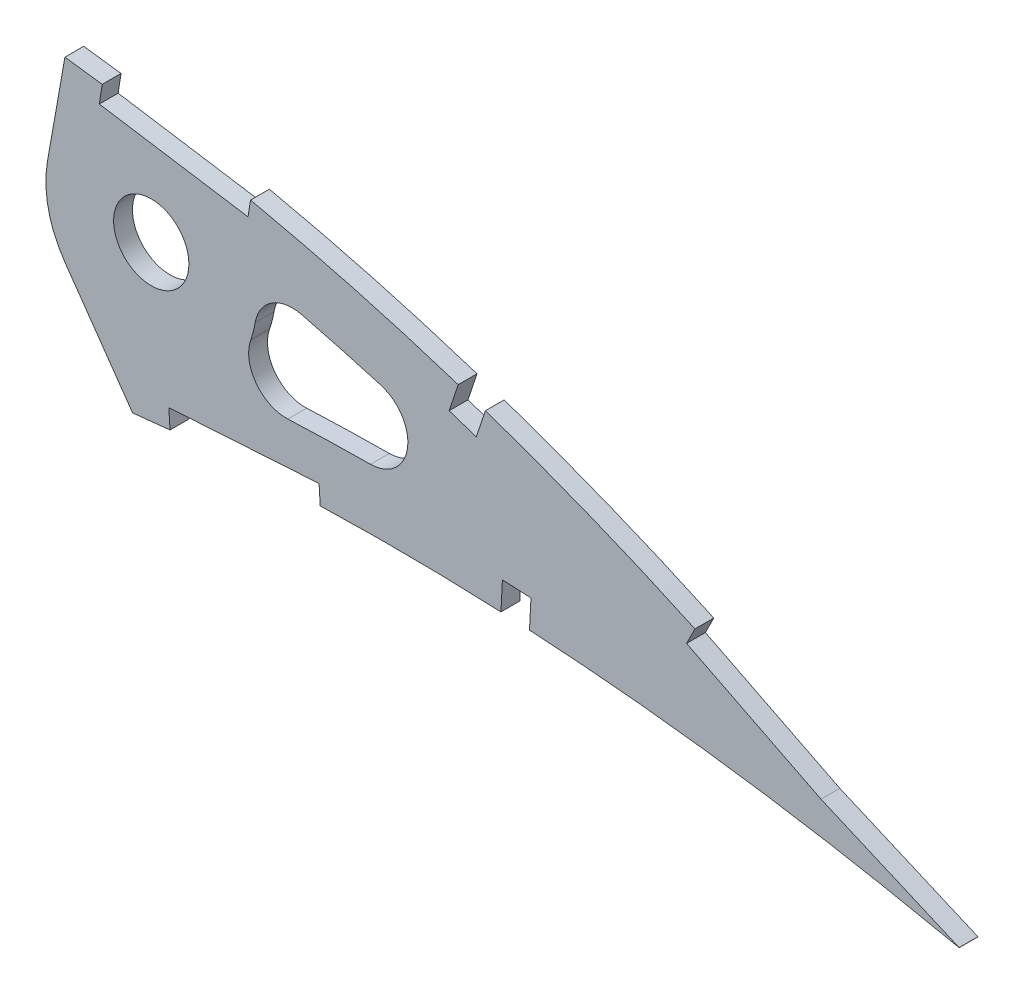
from build123d import *

# Parameters (mm, degrees)
BOSS_EXTRUDE1_DEPTH = 3.175
SKETCH5_R           = 6.35
CUT_EXTRUDE5_DEPTH  = 495.005666426
CUT_EXTRUDE6_DEPTH  = 7.62
FILLET1_R           = 6.35


with BuildPart() as part:
    # Sketch1 → Boss-Extrude1 (new body)
    with BuildSketch(Plane.XY):
        with BuildLine():
            Line((485.587399664, -0.75798934), (490.147728055, -1.684578565))
            Line((490.147728055, -1.684578565), (486.193791136, 0.75798934))
            add(Edge.make_bspline(
                [(486.193791136, 0.75798934), (486.156545565, 0.780998011), (486.007707871, 0.872943377), (485.672349582, 1.078647636), (485.113908292, 1.42125844), (484.332139179, 1.898395939), (483.327649378, 2.508793191), (482.099933618, 3.248176053), (480.649758178, 4.11414228), (478.977474042, 5.102596174), (477.083252712, 6.208909725), (474.9678154, 7.428600903), (472.631346146, 8.754764469), (470.074750091, 10.181981707), (467.298904376, 11.703464898), (464.304334104, 13.312342155), (461.092111509, 15.00042968), (457.663469746, 16.760467008), (454.019033833, 18.582734695), (450.160522056, 20.459648763), (446.08922006, 22.381851369), (441.806517314, 24.339086509), (437.314874314, 26.32337623), (432.615532729, 28.322383702), (427.711170694, 30.327448406), (422.603876177, 32.32715893), (417.296673201, 34.312408193), (411.791609239, 36.270335128), (406.092799427, 38.19238362), (400.203008281, 40.066067188), (394.126447785, 41.881210299), (387.866648542, 43.626044211), (381.42882875, 45.291620487), (374.81707141, 46.865809768), (368.036980395, 48.338075006), (361.093945075, 49.699552264), (353.993788332, 50.936649002), (346.7561854, 52.048400815), (339.497587697, 52.97319004), (332.253923966, 53.880196397), (325.021047815, 54.732245847), (317.699770737, 55.548201081), (310.297136308, 56.323468086), (302.820487344, 57.055622539), (295.277392798, 57.741504683), (287.675691417, 58.379102964), (280.022738792, 58.964804598), (272.326604726, 59.497707184), (264.594897726, 59.973125915), (256.835853078, 60.39070372), (249.05734719, 60.747528421), (241.267474913, 61.041141246), (233.474507978, 61.269769861), (225.686535745, 61.431223873), (217.911990598, 61.524488163), (210.158959277, 61.547014441), (202.435870244, 61.498399603), (194.750810842, 61.376974546), (187.112218127, 61.181076903), (179.528190462, 60.910341158), (172.006928802, 60.56488465), (164.556668167, 60.141814477), (157.185490761, 59.643826715), (149.90160498, 59.068829465), (142.713013757, 58.416669795), (135.627250794, 57.690066178), (128.652204991, 56.887042275), (121.795351463, 56.009883049), (115.064190238, 55.060308222), (108.466273869, 54.03780049), (102.008670179, 52.945313451), (95.69834878, 51.783964779), (89.541985966, 50.557159213), (83.546284377, 49.265216856), (77.717590812, 47.912013041), (72.061962755, 46.499905586), (66.585479912, 45.031479446), (61.293693841, 43.510258272), (56.191955701, 41.93969324), (51.286212878, 40.321510147), (46.580173058, 38.661844322), (42.079617138, 36.961873954), (37.787992638, 35.226836263), (33.71032906, 33.459100147), (29.849672544, 31.664054679), (26.210392495, 29.843743399), (22.795082621, 28.003266258), (19.607171667, 26.145445317), (16.649728276, 24.273731457), (13.923995526, 22.392872215), (11.433731376, 20.504048278), (9.179791317, 18.61203256), (7.163601692, 16.719706143), (5.388044474, 14.828372521), (3.853055719, 12.941362387), (2.560647106, 11.060170164), (1.511042845, 9.186575935), (0.706617001, 7.321940679), (0.14657185, 5.467313049), (-0.159993132, 3.625430402), (-0.236298987, 1.794816138), (-0.078648638, 0.597378122), (0, 0)],
                knots=[0, 0, 0, 0, 0.00025409, 0.001015373, 0.002283359, 0.004056577, 0.006330982, 0.009105274, 0.012374489, 0.016134023, 0.020379661, 0.025105976, 0.030306237, 0.035972206, 0.042099522, 0.048678064, 0.055701664, 0.063160184, 0.071045824, 0.079349827, 0.08806291, 0.097175757, 0.106678111, 0.116561573, 0.126814276, 0.137428301, 0.148393618, 0.15969976, 0.171338125, 0.183297699, 0.195569604, 0.208143556, 0.221011593, 0.234161831, 0.24758745, 0.261276822, 0.27522271, 0.289414144, 0.3037712, 0.317689226, 0.331784111, 0.346039677, 0.36044387, 0.374982721, 0.389640454, 0.404403317, 0.4192566, 0.434186749, 0.449177265, 0.464214782, 0.479284009, 0.49436974, 0.509457833, 0.524532346, 0.53957932, 0.554582984, 0.569529546, 0.584403417, 0.599190992, 0.613876838, 0.628447475, 0.642888675, 0.657186054, 0.671325546, 0.685294014, 0.699078147, 0.712665095, 0.726042645, 0.739197713, 0.752117586, 0.764792042, 0.777208152, 0.789355685, 0.80122396, 0.812803686, 0.824082909, 0.835054602, 0.845709571, 0.856037853, 0.866033834, 0.875688843, 0.884997719, 0.893953426, 0.902552897, 0.910789386, 0.918660734, 0.926166253, 0.933302626, 0.94007122, 0.94647478, 0.952517526, 0.958204819, 0.963546652, 0.9685566, 0.973249913, 0.977651041, 0.981787043, 0.985694226, 0.989415109, 0.993001157, 0.996508416, 1, 1, 1, 1], degree=3))
            add(Edge.make_bspline(
                [(0, 0), (0.124852845, -0.589388692), (0.375132337, -1.770874799), (1.055109044, -3.471725282), (1.954345773, -5.106735278), (3.091715472, -6.671561797), (4.459655687, -8.165777182), (6.055145152, -9.59093561), (7.876619233, -10.946270738), (9.92169391, -12.231165798), (12.187398396, -13.446984767), (14.671186068, -14.592971696), (17.370792198, -15.668768481), (20.283275494, -16.672937055), (23.405075375, -17.607006726), (26.733223776, -18.468701274), (30.263936284, -19.259225009), (33.993816996, -19.976560109), (37.918801514, -20.621435301), (42.034812323, -21.193489669), (46.337624631, -21.693081077), (50.82301706, -22.119161118), (55.4865531, -22.47264634), (60.323584549, -22.753771214), (65.329416188, -22.963427152), (70.499252954, -23.100817142), (75.828031579, -23.168083162), (81.310936338, -23.16623498), (86.942603653, -23.09477832), (92.718222737, -22.957660649), (98.632251256, -22.754013473), (104.679350026, -22.486301136), (110.854064483, -22.157217858), (117.150856575, -21.767879174), (123.564184912, -21.320010643), (130.088480981, -20.817203984), (136.717818035, -20.260713235), (143.446414433, -19.653782206), (150.268313286, -18.999449162), (157.177620607, -18.29978506), (164.168237687, -17.558081099), (171.233938121, -16.77674083), (178.368711149, -15.959932594), (185.566039209, -15.10913432), (192.819836156, -14.229203613), (200.123278023, -13.321821748), (207.470257634, -12.390483576), (214.854167095, -11.43957439), (222.268093801, -10.46898568), (229.705802131, -9.485632582), (237.16011938, -8.488705064), (244.624557097, -7.483330472), (252.092205531, -6.472633763), (259.555791095, -5.456925983), (267.00875308, -4.440416464), (274.444177456, -3.425895825), (281.854781181, -2.413456633), (289.233859631, -1.408131206), (296.573982386, -0.40979664), (303.868380953, 0.579523), (311.110065241, 1.55687475), (318.292203182, 2.521024953), (325.407385919, 3.471363717), (332.448454941, 4.408247897), (339.302915498, 5.303240759), (345.952856872, 6.204000824), (352.420688138, 6.942424504), (358.80798662, 7.572695641), (365.121387221, 8.089431053), (371.353308903, 8.500064921), (377.496611311, 8.807531395), (383.543972889, 9.016123146), (389.487754946, 9.132028332), (395.320533551, 9.158188245), (401.034347101, 9.102945563), (406.621764277, 8.970753247), (412.074986888, 8.767544827), (417.386407281, 8.500176147), (422.548480993, 8.175935919), (427.553458197, 7.799606866), (432.394364707, 7.379974648), (437.06373176, 6.923182232), (441.554389355, 6.434448486), (445.859785012, 5.92401425), (449.973027478, 5.395240442), (453.887929886, 4.85681652), (457.598190253, 4.314198878), (461.097932514, 3.774315295), (464.381658048, 3.242315892), (467.444062607, 2.72526199), (470.280349076, 2.227984348), (472.885595604, 1.755339323), (475.25618804, 1.313290259), (477.38744454, 0.904033197), (479.2765147, 0.534312721), (480.919885909, 0.205760173), (482.315149055, -0.076995438), (483.459867496, -0.312838295), (484.352302675, -0.497896754), (484.990691913, -0.632466588), (485.3743447, -0.712542465), (485.54480657, -0.748903783), (485.587399664, -0.75798934)],
                knots=[0, 0, 0, 0, 0.003638255, 0.007293231, 0.011028136, 0.014901081, 0.018963272, 0.023258475, 0.027820626, 0.032679082, 0.03785316, 0.043361875, 0.049214679, 0.055422346, 0.061988786, 0.068918036, 0.076211157, 0.083868392, 0.091887411, 0.100265912, 0.108999867, 0.118084529, 0.127514843, 0.13728527, 0.147387917, 0.157816481, 0.168563473, 0.179619128, 0.190977373, 0.202626974, 0.214560478, 0.226767249, 0.239236417, 0.251959004, 0.264923894, 0.278119703, 0.291536035, 0.30516028, 0.318980685, 0.332985499, 0.34716279, 0.361498603, 0.375980747, 0.390597192, 0.405332593, 0.420174823, 0.435109533, 0.450124276, 0.465203068, 0.480333154, 0.495500583, 0.510689775, 0.525887334, 0.541078314, 0.556247233, 0.571381785, 0.58646604, 0.601484516, 0.616424329, 0.631269423, 0.646006524, 0.660620684, 0.675098188, 0.689422858, 0.703581824, 0.716907564, 0.730009274, 0.742952128, 0.755725558, 0.768319952, 0.780724337, 0.792926528, 0.804916041, 0.816679084, 0.828203524, 0.8394749, 0.850481359, 0.861207697, 0.871639326, 0.881763414, 0.891563605, 0.901027364, 0.910138977, 0.918883976, 0.927249278, 0.935221104, 0.942784738, 0.949928188, 0.956638464, 0.962904204, 0.968712288, 0.974054485, 0.978918432, 0.983297218, 0.987180246, 0.990560674, 0.993433357, 0.995790626, 0.997629587, 0.998945816, 0.999736592, 1, 1, 1, 1], degree=3))
        make_face()
    extrude(amount=BOSS_EXTRUDE1_DEPTH)

    # Sketch5 → Cut-Extrude5 (cut, through all)
    with BuildSketch(Plane.XY.offset(3.175)):
        with BuildLine():
            ThreePointArc((339.268396528, 23.034385848), (336.474376869, 29.38427855), (336.323038027, 36.320039485))
            Line((336.323038027, 36.320039485), (337.498487212, 42.986343077))
            add(Edge.make_bspline(
                [(337.498487212, 42.986343077), (336.278152634, 43.139647538), (332.391488029, 43.620196944), (325.904912581, 44.406094195), (315.298273289, 45.600903446), (296.745114657, 47.495867579), (270.181386899, 49.613569583), (238.27192568, 51.14645634), (206.363976303, 51.567435326), (174.513649112, 50.743648416), (142.802349779, 48.487430078), (116.596999548, 45.208024241), (95.874041908, 41.555390759), (80.504896847, 38.236322777), (65.37423895, 34.251152388), (53.057700329, 30.27887773), (43.488361933, 26.624824058), (36.49970262, 23.615604654), (29.771075012, 20.304580366), (23.420053123, 16.651798981), (17.654269216, 12.627589389), (13.676813746, 8.984261083), (11.42081563, 6.111975482), (10.531325996, 4.511244861), (10.142088352, 3.437918571), (10.030186656, 2.955882386), (9.973111845, 2.506731868), (9.964230355, 2.311379475), (9.965626151, 2.250431179), (9.965748425, 2.235894656), (9.979062349, 2.081139294), (9.999561737, 1.900153689), (10.01479215, 1.776251195), (10.022081403, 1.718513094)],
                knots=[0.305053467, 0.305053467, 0.305053467, 0.305053467, 0.312228521, 0.327839947, 0.343451373, 0.374674225, 0.43711993, 0.499565634, 0.562011338, 0.624457042, 0.686902747, 0.749348451, 0.780571303, 0.811794155, 0.843017007, 0.874239859, 0.889851285, 0.905462711, 0.921074137, 0.936685563, 0.952296989, 0.967908416, 0.975714129, 0.983519842, 0.987422698, 0.991325555, 0.993276983, 0.995228411, 0.996204125, 0.997179839, 0.998155554, 0.998643411, 0.999131268, 0.999131268, 0.999131268, 0.999131268], degree=3))
            add(Edge.make_bspline(
                [(10.022081403, 1.718513094), (10.034021258, 1.663582679), (10.059908876, 1.546240109), (10.099905998, 1.372347634), (10.138895711, 1.219939682), (10.147564794, 1.192139161), (10.162831137, 1.145171589), (10.226818816, 0.98158475), (10.420263023, 0.586195803), (10.678139358, 0.166718059), (11.33982612, -0.673027549), (12.617971369, -1.866961157), (15.48090731, -3.803568819), (20.158618023, -5.983515642), (26.591355841, -8.02264804), (33.467520416, -9.595157776), (40.598540213, -10.784979213), (47.887704976, -11.668508509), (57.743873902, -12.505919916), (70.236833849, -13.024977368), (85.364632385, -13.028238208), (100.567613906, -12.557423456), (120.895656611, -11.432950706), (146.365626994, -9.289849376), (176.964190047, -5.968711499), (207.58885852, -2.174326754), (238.230999695, 1.888378785), (268.90490631, 6.071067455), (294.483360923, 9.565962325), (312.408562259, 11.98457976), (322.649403588, 13.353359362), (329.053674924, 14.207079569), (334.190701115, 14.88180207), (338.002648093, 15.383326298), (341.277737229, 15.824216257), (343.326113059, 16.089556081), (344.065613823, 16.18324953)],
                knots=[0.000904794, 0.000904794, 0.000904794, 0.000904794, 0.001392633, 0.001880473, 0.002856152, 0.00383183, 0.004807509, 0.006758867, 0.008710225, 0.012612941, 0.016515656, 0.024321088, 0.032126519, 0.047737381, 0.063348244, 0.078959107, 0.094569969, 0.110180832, 0.125791694, 0.15701342, 0.188235145, 0.21945687, 0.250678595, 0.313122046, 0.375565496, 0.438008946, 0.500452397, 0.562895847, 0.625339298, 0.656561023, 0.672171885, 0.687782748, 0.695588179, 0.703393611, 0.711199042, 0.71558295, 0.71558295, 0.71558295, 0.71558295], degree=3))
            Line((344.065613823, 16.18324953), (339.268396528, 23.034385848))
        make_face()
        with Locations((353.832919875, 33.232574886)):
            Circle(SKETCH5_R)
        with BuildLine():
            add(Edge.make_bspline(
                [(337.498487212, 42.986343077), (336.278152634, 43.139647538), (332.391488029, 43.620196944), (325.904912581, 44.406094195), (315.298273289, 45.600903446), (296.745114657, 47.495867579), (270.181386899, 49.613569583), (238.27192568, 51.14645634), (206.363976303, 51.567435326), (174.513649112, 50.743648416), (142.802349779, 48.487430078), (116.596999548, 45.208024241), (95.874041908, 41.555390759), (80.504896847, 38.236322777), (65.37423895, 34.251152388), (53.057700329, 30.27887773), (43.488361933, 26.624824058), (36.49970262, 23.615604654), (29.771075012, 20.304580366), (23.420053123, 16.651798981), (17.654269216, 12.627589389), (13.676813746, 8.984261083), (11.42081563, 6.111975482), (10.531325996, 4.511244861), (10.142088352, 3.437918571), (10.030186656, 2.955882386), (9.973111845, 2.506731868), (9.964230355, 2.311379475), (9.965626151, 2.250431179), (9.965748425, 2.235894656), (9.979062349, 2.081139294), (9.999561737, 1.900153689), (10.01479215, 1.776251195), (10.022081403, 1.718513094)],
                knots=[0.305053467, 0.305053467, 0.305053467, 0.305053467, 0.312228521, 0.327839947, 0.343451373, 0.374674225, 0.43711993, 0.499565634, 0.562011338, 0.624457042, 0.686902747, 0.749348451, 0.780571303, 0.811794155, 0.843017007, 0.874239859, 0.889851285, 0.905462711, 0.921074137, 0.936685563, 0.952296989, 0.967908416, 0.975714129, 0.983519842, 0.987422698, 0.991325555, 0.993276983, 0.995228411, 0.996204125, 0.997179839, 0.998155554, 0.998643411, 0.999131268, 0.999131268, 0.999131268, 0.999131268], degree=3))
            Line((337.498487212, 42.986343077), (339.264168094, 53.000016967))
            add(Edge.make_bspline(
                [(339.264168094, 53.000016967), (336.937656328, 53.293724364), (332.201167732, 53.886411202), (325.021047815, 54.732245847), (317.699770737, 55.548201081), (310.297136308, 56.323468086), (302.820487344, 57.055622539), (295.277392798, 57.741504683), (287.675691417, 58.379102964), (280.022738792, 58.964804598), (272.326604726, 59.497707184), (264.594897726, 59.973125915), (256.835853078, 60.39070372), (249.05734719, 60.747528421), (241.267474913, 61.041141246), (233.474507978, 61.269769861), (225.686535745, 61.431223873), (217.911990598, 61.524488163), (210.158959277, 61.547014441), (202.435870244, 61.498399603), (194.750810842, 61.376974546), (187.112218127, 61.181076903), (179.528190462, 60.910341158), (172.006928802, 60.56488465), (164.556668167, 60.141814477), (157.185490761, 59.643826715), (149.90160498, 59.068829465), (142.713013757, 58.416669795), (135.627250794, 57.690066178), (128.652204991, 56.887042275), (121.795351463, 56.009883049), (115.064190238, 55.060308222), (108.466273869, 54.03780049), (102.008670179, 52.945313451), (95.69834878, 51.783964779), (89.541985966, 50.557159213), (83.546284377, 49.265216856), (77.717590812, 47.912013041), (72.061962755, 46.499905586), (66.585479912, 45.031479446), (61.293693841, 43.510258272), (56.191955701, 41.93969324), (51.286212878, 40.321510147), (46.580173058, 38.661844322), (42.079617138, 36.961873954), (37.787992638, 35.226836263), (33.71032906, 33.459100147), (29.849672544, 31.664054679), (26.210392495, 29.843743399), (22.795082621, 28.003266258), (19.607171667, 26.145445317), (16.649728276, 24.273731457), (13.923995526, 22.392872215), (11.433731376, 20.504048278), (9.179791317, 18.61203256), (7.163601692, 16.719706143), (5.388044474, 14.828372521), (3.853055719, 12.941362387), (2.560647106, 11.060170164), (1.511042845, 9.186575935), (0.706617001, 7.321940679), (0.14657185, 5.467313049), (-0.159993132, 3.625430402), (-0.236298987, 1.794816138), (-0.078648638, 0.597378122), (0, 0)],
                knots=[0.304079504, 0.304079504, 0.304079504, 0.304079504, 0.317689226, 0.331784111, 0.346039677, 0.36044387, 0.374982721, 0.389640454, 0.404403317, 0.4192566, 0.434186749, 0.449177265, 0.464214782, 0.479284009, 0.49436974, 0.509457833, 0.524532346, 0.53957932, 0.554582984, 0.569529546, 0.584403417, 0.599190992, 0.613876838, 0.628447475, 0.642888675, 0.657186054, 0.671325546, 0.685294014, 0.699078147, 0.712665095, 0.726042645, 0.739197713, 0.752117586, 0.764792042, 0.777208152, 0.789355685, 0.80122396, 0.812803686, 0.824082909, 0.835054602, 0.845709571, 0.856037853, 0.866033834, 0.875688843, 0.884997719, 0.893953426, 0.902552897, 0.910789386, 0.918660734, 0.926166253, 0.933302626, 0.94007122, 0.94647478, 0.952517526, 0.958204819, 0.963546652, 0.9685566, 0.973249913, 0.977651041, 0.981787043, 0.985694226, 0.989415109, 0.993001157, 0.996508416, 1, 1, 1, 1], degree=3))
            add(Edge.make_bspline(
                [(0, 0), (0.124852845, -0.589388692), (0.375132337, -1.770874799), (1.055109044, -3.471725282), (1.954345773, -5.106735278), (3.091715472, -6.671561797), (4.459655687, -8.165777182), (6.055145152, -9.59093561), (7.876619233, -10.946270738), (9.92169391, -12.231165798), (12.187398396, -13.446984767), (14.671186068, -14.592971696), (17.370792198, -15.668768481), (20.283275494, -16.672937055), (23.405075375, -17.607006726), (26.733223776, -18.468701274), (30.263936284, -19.259225009), (33.993816996, -19.976560109), (37.918801514, -20.621435301), (42.034812323, -21.193489669), (46.337624631, -21.693081077), (50.82301706, -22.119161118), (55.4865531, -22.47264634), (60.323584549, -22.753771214), (65.329416188, -22.963427152), (70.499252954, -23.100817142), (75.828031579, -23.168083162), (81.310936338, -23.16623498), (86.942603653, -23.09477832), (92.718222737, -22.957660649), (98.632251256, -22.754013473), (104.679350026, -22.486301136), (110.854064483, -22.157217858), (117.150856575, -21.767879174), (123.564184912, -21.320010643), (130.088480981, -20.817203984), (136.717818035, -20.260713235), (143.446414433, -19.653782206), (150.268313286, -18.999449162), (157.177620607, -18.29978506), (164.168237687, -17.558081099), (171.233938121, -16.77674083), (178.368711149, -15.959932594), (185.566039209, -15.10913432), (192.819836156, -14.229203613), (200.123278023, -13.321821748), (207.470257634, -12.390483576), (214.854167095, -11.43957439), (222.268093801, -10.46898568), (229.705802131, -9.485632582), (237.16011938, -8.488705064), (244.624557097, -7.483330472), (252.092205531, -6.472633763), (259.555791095, -5.456925983), (267.00875308, -4.440416464), (274.444177456, -3.425895825), (281.854781181, -2.413456633), (289.233859631, -1.408131206), (296.573982386, -0.40979664), (303.868380953, 0.579523), (311.110065241, 1.55687475), (318.292203182, 2.521024953), (325.407385919, 3.471363717), (332.448454941, 4.408247897), (339.302915498, 5.303240759), (345.365279013, 6.124411149), (349.116343239, 6.563474717), (350.680088226, 6.736801095)],
                knots=[0, 0, 0, 0, 0.003638255, 0.007293231, 0.011028136, 0.014901081, 0.018963272, 0.023258475, 0.027820626, 0.032679082, 0.03785316, 0.043361875, 0.049214679, 0.055422346, 0.061988786, 0.068918036, 0.076211157, 0.083868392, 0.091887411, 0.100265912, 0.108999867, 0.118084529, 0.127514843, 0.13728527, 0.147387917, 0.157816481, 0.168563473, 0.179619128, 0.190977373, 0.202626974, 0.214560478, 0.226767249, 0.239236417, 0.251959004, 0.264923894, 0.278119703, 0.291536035, 0.30516028, 0.318980685, 0.332985499, 0.34716279, 0.361498603, 0.375980747, 0.390597192, 0.405332593, 0.420174823, 0.435109533, 0.450124276, 0.465203068, 0.480333154, 0.495500583, 0.510689775, 0.525887334, 0.541078314, 0.556247233, 0.571381785, 0.58646604, 0.601484516, 0.616424329, 0.631269423, 0.646006524, 0.660620684, 0.675098188, 0.689422858, 0.703581824, 0.716907564, 0.726423125, 0.726423125, 0.726423125, 0.726423125], degree=3))
            Line((350.680088226, 6.736801095), (344.065613823, 16.18324953))
            add(Edge.make_bspline(
                [(10.022081403, 1.718513094), (10.034021258, 1.663582679), (10.059908876, 1.546240109), (10.099905998, 1.372347634), (10.138895711, 1.219939682), (10.147564794, 1.192139161), (10.162831137, 1.145171589), (10.226818816, 0.98158475), (10.420263023, 0.586195803), (10.678139358, 0.166718059), (11.33982612, -0.673027549), (12.617971369, -1.866961157), (15.48090731, -3.803568819), (20.158618023, -5.983515642), (26.591355841, -8.02264804), (33.467520416, -9.595157776), (40.598540213, -10.784979213), (47.887704976, -11.668508509), (57.743873902, -12.505919916), (70.236833849, -13.024977368), (85.364632385, -13.028238208), (100.567613906, -12.557423456), (120.895656611, -11.432950706), (146.365626994, -9.289849376), (176.964190047, -5.968711499), (207.58885852, -2.174326754), (238.230999695, 1.888378785), (268.90490631, 6.071067455), (294.483360923, 9.565962325), (312.408562259, 11.98457976), (322.649403588, 13.353359362), (329.053674924, 14.207079569), (334.190701115, 14.88180207), (338.002648093, 15.383326298), (341.277737229, 15.824216257), (343.326113059, 16.089556081), (344.065613823, 16.18324953)],
                knots=[0.000904794, 0.000904794, 0.000904794, 0.000904794, 0.001392633, 0.001880473, 0.002856152, 0.00383183, 0.004807509, 0.006758867, 0.008710225, 0.012612941, 0.016515656, 0.024321088, 0.032126519, 0.047737381, 0.063348244, 0.078959107, 0.094569969, 0.110180832, 0.125791694, 0.15701342, 0.188235145, 0.21945687, 0.250678595, 0.313122046, 0.375565496, 0.438008946, 0.500452397, 0.562895847, 0.625339298, 0.656561023, 0.672171885, 0.687782748, 0.695588179, 0.703393611, 0.711199042, 0.71558295, 0.71558295, 0.71558295, 0.71558295], degree=3))
        make_face()
        with BuildLine():
            add(Edge.make_bspline(
                [(431.792204981, 17.627124909), (429.499446283, 18.60875342), (417.537197355, 23.583145799), (400.38239885, 29.636231351), (382.285825986, 34.651124284), (374.18178654, 36.577831496), (371.152246999, 37.253682689)],
                knots=[0.11000544, 0.11000544, 0.11000544, 0.11000544, 0.124891408, 0.187337113, 0.218559965, 0.237120282, 0.237120282, 0.237120282, 0.237120282], degree=3))
            ThreePointArc((371.152246999, 37.253682689), (371.497376225, 35.256279871), (371.612919875, 33.232574886))
            ThreePointArc((371.612919875, 33.232574886), (369.366310929, 24.581438407), (363.194228944, 18.116547216))
            add(Edge.make_bspline(
                [(363.194228944, 18.116547216), (367.949696757, 18.482461612), (377.992772166, 19.074473867), (398.645234284, 19.522094037), (416.768618232, 18.862166517), (429.549739053, 17.826232335), (431.792204981, 17.627124909)],
                knots=[0.753339218, 0.753339218, 0.753339218, 0.753339218, 0.781447924, 0.812669649, 0.875113099, 0.888413857, 0.888413857, 0.888413857, 0.888413857], degree=3))
        make_face()
    extrude(amount=-CUT_EXTRUDE5_DEPTH, mode=Mode.SUBTRACT)

    # Sketch6 → Cut-Extrude6 (cut)
    with BuildSketch(Plane(origin=(0, 0, 0), x_dir=(-1, 0, 0), z_dir=(0, 0, -1))):
        Polygon((-417.650295847, 8.475310149), (-417.650295847, 7.612206053), (-412.830655019, 7.859821957), (-412.830655019, 8.722926053), (-413.078270924, 13.54256688), (-417.897911751, 13.294950976), align=None)
        Polygon((-491.421363462, 1.231455898), (-468.179228096, 11.238892945), (-445.576649003, 22.617331862), (-444.149007278, 19.781408127), (-466.83639716, 8.36027433), (-490.165740173, -1.684711979), align=None)
        Polygon((-382.347442541, 8.975869989), (-382.347442541, 7.859821957), (-356.997242094, 6.290346225), (-356.997242094, 7.386352148), (-356.798552364, 10.555127204), (-382.14875281, 12.144645045), align=None)
        Polygon((-408.674358859, 32.228266711), (-410.201609569, 36.806230537), (-405.623645744, 38.333481247), (-404.096395034, 33.755517421), align=None)
        Polygon((-370.162778652, 45.112121424), (-370.654947588, 48.248742176), (-345.561981574, 52.186093662), (-345.069812638, 49.04947291), align=None)
    extrude(amount=-CUT_EXTRUDE6_DEPTH, mode=Mode.SUBTRACT)


with BuildPart() as cut_extrude6_kept_piece:
    # of the separate pieces the step leaves, the one the design keeps (cut_extrude6_pieces_kept)
    add(part.part.solids().sort_by_distance((485.587399664, -0.75798934, 0))[0])

    # Fillet1
    fillet1_edges = [cut_extrude6_kept_piece.edges().sort_by_distance(p)[0] for p in [
        (431.792204981, 17.627124909, 1.5875),
        (363.194228944, 18.116547216, 1.5875),
        (371.152246999, 37.253682689, 1.5875),
    ]]
    fillet(fillet1_edges, radius=FILLET1_R)


solid = cut_extrude6_kept_piece.part
